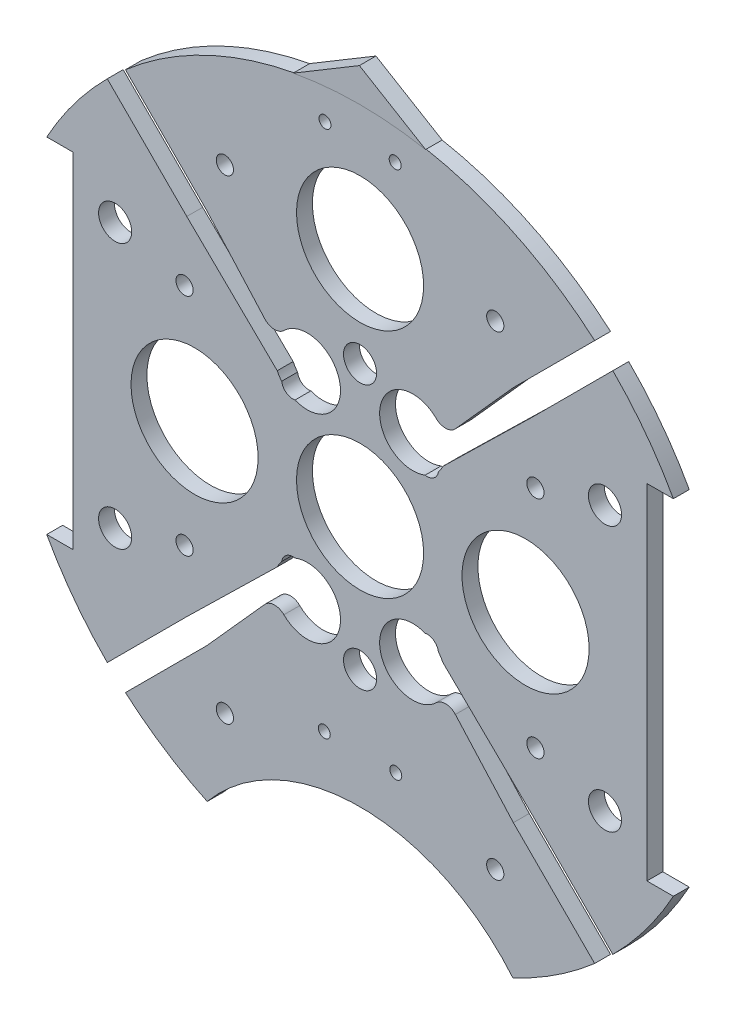
from build123d import *

# Parameters (mm, degrees)
BOSS_EXTRUDE2_DEPTH      = 3.048
SKETCH4_R                = 38.1
CUT_EXTRUDE3_DEPTH       = 4.048
BOSS_EXTRUDE3_DEPTH      = 3.175
SKETCH12_R               = 1.143
CUT_EXTRUDE9_DEPTH       = 4.175
SKETCH15_R               = 1.651
CUT_EXTRUDE12_DEPTH      = 75.692
SKETCH17_R               = 1.651
CUT_EXTRUDE14_DEPTH      = 97.79
SKETCH18_R               = 12.192
CUT_EXTRUDE15_DEPTH      = 35.56
SKETCH19_R               = 3.175
CUT_EXTRUDE16_DEPTH      = 103.378
CUT_EXTRUDE16_DEPTH_BACK = 48.768
SKETCH5_R                = 12.192
CUT_EXTRUDE6_DEPTH       = 4.175
FILLET1_R                = 2.54
SKETCH20_R               = 1.143
CUT_EXTRUDE17_DEPTH      = 4.175


with BuildPart() as part:
    # Sketch1 → Boss-Extrude2 (new body)
    with BuildSketch(Plane.XY):
        with BuildLine():
            Line((-60.107370596, 33.02), (-55.027370596, 33.02))
            Line((-55.027370596, 33.02), (-55.027370596, -33.02))
            Line((-55.027370596, -33.02), (-60.107370596, -33.02))
            ThreePointArc((-60.107370596, -33.02), (0, -68.58), (60.107370596, -33.02))
            Line((60.107370596, -33.02), (55.027370596, -33.02))
            Line((55.027370596, -33.02), (55.027370596, 33.02))
            Line((55.027370596, 33.02), (60.107370596, 33.02))
            ThreePointArc((60.107370596, 33.02), (0, 68.58), (-60.107370596, 33.02))
        make_face()
    extrude(amount=BOSS_EXTRUDE2_DEPTH)

    # Sketch4 → Cut-Extrude3 (cut, through all)
    with BuildSketch(Plane(origin=(0, 0, 0), x_dir=(-1, 0, 0), z_dir=(0, 0, -1))):
        with Locations((0, -86.312058398)):
            Circle(SKETCH4_R)
    extrude(amount=-CUT_EXTRUDE3_DEPTH, mode=Mode.SUBTRACT)

    # Sketch9 → Boss-Extrude3 (add)
    with BuildSketch(Plane(origin=(0, 0, 0), x_dir=(-1, 0, 0), z_dir=(0, 0, -1))):
        with BuildLine():
            Line((12.7, 67.39381574), (0, 75))
            Line((0, 75), (-12.7, 67.39381574))
            ThreePointArc((-12.7, 67.39381574), (0, 68.58), (12.7, 67.39381574))
        make_face()
    extrude(amount=-BOSS_EXTRUDE3_DEPTH)

    # Sketch12 → Cut-Extrude9 (cut, through all)
    with BuildSketch(Plane(origin=(0, 0, 0), x_dir=(-1, 0, 0), z_dir=(0, 0, -1))):
        with Locations((6.731, 62.23)):
            Circle(SKETCH12_R)
        with Locations((-6.731, 62.23)):
            Circle(SKETCH12_R)
    extrude(amount=-CUT_EXTRUDE9_DEPTH, mode=Mode.SUBTRACT)

    # Sketch15 → Cut-Extrude12 (cut)
    with BuildSketch(Plane(origin=(30.092005081, 4.08352975, -3.048), x_dir=(-1, 0, 0), z_dir=(0, 0, -1))):
        with Locations((63.757223581, 17.50647025)):
            Circle(SKETCH15_R)
        with Locations((63.757223581, -25.67352975)):
            Circle(SKETCH15_R)
        with Locations((-3.552776419, -25.67352975)):
            Circle(SKETCH15_R)
        with Locations((-3.552776419, 17.50647025)):
            Circle(SKETCH15_R)
    extrude(amount=-CUT_EXTRUDE12_DEPTH, mode=Mode.SUBTRACT)

    # Sketch17 → Cut-Extrude14 (cut)
    with BuildSketch(Plane(origin=(30.092005081, 4.08352975, -33.0835), x_dir=(-1, 0, 0), z_dir=(0, 0, -1))):
        with Locations((4.154396091, -49.728759131)):
            Circle(SKETCH17_R)
        with Locations((56.02961407, -49.728759131)):
            Circle(SKETCH17_R)
        with Locations((4.154396091, 41.38247025)):
            Circle(SKETCH17_R)
        with Locations((56.02961407, 41.38247025)):
            Circle(SKETCH17_R)
    extrude(amount=-CUT_EXTRUDE14_DEPTH, mode=Mode.SUBTRACT)

    # Sketch18 → Cut-Extrude15 (cut)
    with BuildSketch(Plane(origin=(0, 0, 0), x_dir=(-1, 0, 0), z_dir=(0, 0, -1))):
        with Locations((31.75, 0)):
            Circle(SKETCH18_R)
        with Locations((-31.75, 0)):
            Circle(SKETCH18_R)
    extrude(amount=-CUT_EXTRUDE15_DEPTH, mode=Mode.SUBTRACT)

    # Sketch19 → Cut-Extrude16 (cut, two sides)
    with BuildSketch(Plane(origin=(30.092005081, 4.08352975, 3.048), x_dir=(-1, 0, 0), z_dir=(0, 0, -1))) as cut_extrude16_sk:
        with Locations((-16.897994919, 21.31647025)):
            Circle(SKETCH19_R)
        with Locations((77.082005081, 21.31647025)):
            Circle(SKETCH19_R)
        with Locations((30.092005081, 21.31647025)):
            Circle(SKETCH19_R)
        with Locations((77.082005081, -29.48352975)):
            Circle(SKETCH19_R)
        with Locations((30.092005081, -29.48352975)):
            Circle(SKETCH19_R)
        with Locations((-16.897994919, -29.48352975)):
            Circle(SKETCH19_R)
    extrude(amount=CUT_EXTRUDE16_DEPTH, mode=Mode.SUBTRACT)
    extrude(cut_extrude16_sk.sketch, amount=-CUT_EXTRUDE16_DEPTH_BACK, mode=Mode.SUBTRACT)

    # Sketch5 → Cut-Extrude6 (cut, through all)
    with BuildSketch(Plane(origin=(0, 0, 0), x_dir=(-1, 0, 0), z_dir=(0, 0, -1))):
        with BuildLine():
            Line((45.125787008, -51.860979099), (48.493383054, -48.493383054))
            Line((48.493383054, -48.493383054), (33.244765274, -33.244765274))
            Line((33.244765274, -33.244765274), (15.887580142, -16.296407899))
            ThreePointArc((15.887580142, -16.296407899), (15.502857332, -15.608744759), (15.036339126, -14.973722712))
            ThreePointArc((15.036339126, -14.973722712), (14.151046139, -13.510927072), (12.484618985, -13.128127778))
            ThreePointArc((12.484618985, -13.128127778), (4.300657145, -21.652046912), (16.112224352, -21.303752637))
            Line((16.112224352, -21.303752637), (29.410338797, -36.145530887))
            Line((29.410338797, -36.145530887), (45.125787008, -51.860979099))
        make_face()
        with BuildLine():
            ThreePointArc((15.036339126, 14.973722712), (15.502857332, 15.608744759), (15.887580142, 16.296407899))
            Line((15.887580142, 16.296407899), (33.244765274, 33.244765274))
            Line((33.244765274, 33.244765274), (48.493383054, 48.493383054))
            Line((48.493383054, 48.493383054), (45.125787008, 51.860979099))
            Line((45.125787008, 51.860979099), (29.410338797, 36.145530887))
            Line((29.410338797, 36.145530887), (16.112224352, 21.303752637))
            ThreePointArc((16.112224352, 21.303752637), (4.300657145, 21.652046912), (12.484618985, 13.128127778))
            ThreePointArc((12.484618985, 13.128127778), (14.151046139, 13.510927072), (15.036339126, 14.973722712))
        make_face()
        with BuildLine():
            ThreePointArc((-12.484618985, 13.128127778), (-4.300657145, 21.652046912), (-16.112224352, 21.303752637))
            Line((-16.112224352, 21.303752637), (-29.410338797, 36.145530887))
            Line((-29.410338797, 36.145530887), (-45.125787008, 51.860979099))
            Line((-45.125787008, 51.860979099), (-48.493383054, 48.493383054))
            Line((-48.493383054, 48.493383054), (-33.244765274, 33.244765274))
            Line((-33.244765274, 33.244765274), (-15.887580142, 16.296407899))
            ThreePointArc((-15.887580142, 16.296407899), (-15.502857332, 15.608744759), (-15.036339126, 14.973722712))
            ThreePointArc((-15.036339126, 14.973722712), (-14.151046139, 13.510927072), (-12.484618985, 13.128127778))
        make_face()
        with BuildLine():
            Line((-45.125787008, -51.860979099), (-29.410338797, -36.145530887))
            Line((-29.410338797, -36.145530887), (-16.112224352, -21.303752637))
            ThreePointArc((-16.112224352, -21.303752637), (-4.300657145, -21.652046912), (-12.484618985, -13.128127778))
            ThreePointArc((-12.484618985, -13.128127778), (-14.151046139, -13.510927072), (-15.036339126, -14.973722712))
            ThreePointArc((-15.036339126, -14.973722712), (-15.502857332, -15.608744759), (-15.887580142, -16.296407899))
            Line((-15.887580142, -16.296407899), (-33.244765274, -33.244765274))
            Line((-33.244765274, -33.244765274), (-48.493383054, -48.493383054))
            Line((-48.493383054, -48.493383054), (-45.125787008, -51.860979099))
        make_face()
        Circle(SKETCH5_R)
        with Locations((0, 44.45)):
            Circle(SKETCH5_R)
    extrude(amount=-CUT_EXTRUDE6_DEPTH, mode=Mode.SUBTRACT)

    # Fillet1
    fillet1_edges = [part.edges().sort_by_distance(p)[0] for p in [
        (-16.112224352, -21.303752637, 1.524),
        (-16.112224352, 21.303752637, 1.524),
        (16.112224352, 21.303752637, 1.524),
        (16.112224352, -21.303752637, 1.524),
    ]]
    fillet(fillet1_edges, radius=FILLET1_R)

    # Sketch20 → Cut-Extrude17 (cut, through all)
    with BuildSketch(Plane(origin=(0, 0, 0), x_dir=(-1, 0, 0), z_dir=(0, 0, -1))):
        with Locations((-6.858, -39.116)):
            Circle(SKETCH20_R)
        with Locations((6.858, -39.116)):
            Circle(SKETCH20_R)
    extrude(amount=-CUT_EXTRUDE17_DEPTH, mode=Mode.SUBTRACT)


solid = part.part
